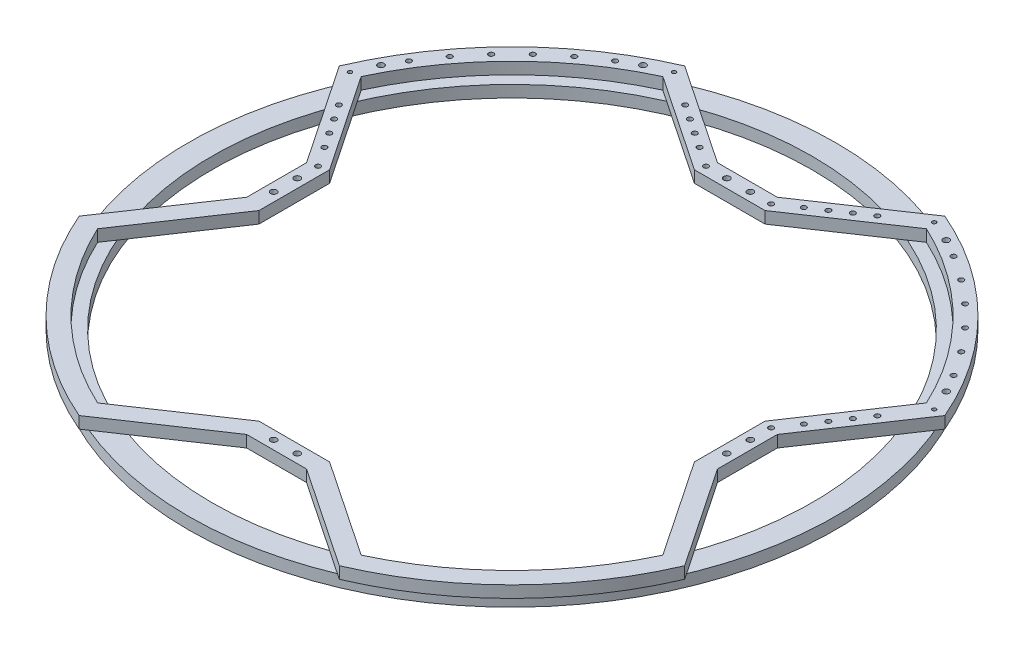
from build123d import *

# Parameters (mm, degrees)
SKETCH_1_R          = 275
SKETCH_1_R_2        = 255
EXTRUDE_1_DEPTH     = 10
EXTRUDE_2_DEPTH     = 10
SKETCH_8_R          = 2.65
SKETCH_8_R_2        = 1.65
SKETCH_8_R_3        = 2.15
CUT_EXTRUDE_1_DEPTH = 21


with BuildPart() as part:
    # 草图1 → 凸台-拉伸1 (new body)
    with BuildSketch(Plane(origin=(0, 0, 0), x_dir=(1, 0, 0), z_dir=(0, 1, 0))):
        Circle(SKETCH_1_R)
        Circle(SKETCH_1_R_2, mode=Mode.SUBTRACT)
    extrude(amount=EXTRUDE_1_DEPTH)


with BuildPart() as body_2:
    # 草图2 → 凸台-拉伸2 (new body)
    with BuildSketch(Plane(origin=(0, 10, 0), x_dir=(1, 0, 0), z_dir=(0, 1, 0))):
        with BuildLine():
            Line((-110.525139894, 257.262887824), (-25.423255477, 200))
            Line((-25.423255477, 200), (0, 200))
            Line((0, 200), (25.423255477, 200))
            Line((25.423255477, 200), (110.525139894, 257.262887824))
            ThreePointArc((110.525139894, 257.262887824), (197.989898732, 197.989898732), (257.262887824, 110.525139894))
            Line((257.262887824, 110.525139894), (200, 25.423255477))
            Line((200, 25.423255477), (200, 0))
            Line((200, 0), (200, -25.423255477))
            Line((200, -25.423255477), (257.262887824, -110.525139894))
            ThreePointArc((257.262887824, -110.525139894), (197.989898732, -197.989898732), (110.525139894, -257.262887824))
            Line((110.525139894, -257.262887824), (25.423255477, -200))
            Line((25.423255477, -200), (0, -200))
            Line((0, -200), (-25.423255477, -200))
            Line((-25.423255477, -200), (-110.525139894, -257.262887824))
            ThreePointArc((-110.525139894, -257.262887824), (-197.989898732, -197.989898732), (-257.262887824, -110.525139894))
            Line((-257.262887824, -110.525139894), (-200, -25.423255477))
            Line((-200, -25.423255477), (-200, 25.423255477))
            Line((-200, 25.423255477), (-257.262887824, 110.525139894))
            ThreePointArc((-257.262887824, 110.525139894), (-197.989898732, 197.989898732), (-110.525139894, 257.262887824))
        make_face()
        with BuildLine():
            Line((0, 185), (30, 185))
            Line((30, 185), (111.993839361, 240.171563565))
            ThreePointArc((111.993839361, 240.171563565), (187.383297014, 187.383297014), (240.171563565, 111.993839361))
            Line((240.171563565, 111.993839361), (185, 30))
            Line((185, 30), (185, 0))
            Line((185, 0), (185, -30))
            Line((185, -30), (240.171563565, -111.993839361))
            ThreePointArc((240.171563565, -111.993839361), (187.383297014, -187.383297014), (111.993839361, -240.171563565))
            Line((111.993839361, -240.171563565), (30, -185))
            Line((30, -185), (0, -185))
            Line((0, -185), (-30, -185))
            Line((-30, -185), (-111.993839361, -240.171563565))
            ThreePointArc((-111.993839361, -240.171563565), (-187.383297014, -187.383297014), (-240.171563565, -111.993839361))
            Line((-240.171563565, -111.993839361), (-185, -30))
            Line((-185, -30), (-185, 30))
            Line((-185, 30), (-240.171563565, 111.993839361))
            ThreePointArc((-240.171563565, 111.993839361), (-187.383297014, 187.383297014), (-111.993839361, 240.171563565))
            Line((-111.993839361, 240.171563565), (-30, 185))
            Line((-30, 185), (0, 185))
        make_face(mode=Mode.SUBTRACT)
    extrude(amount=EXTRUDE_2_DEPTH)

    # 草图8 → 切除-拉伸1 (cut, through all)
    with BuildSketch(Plane(origin=(0, 20, 0), x_dir=(1, 0, 0), z_dir=(0, 1, 0))):
        with Locations((-10, 192.5)):
            Circle(SKETCH_8_R)
        with Locations((10, 192.5)):
            Circle(SKETCH_8_R)
        with Locations((-10, -192.5)):
            Circle(SKETCH_8_R)
        with Locations((10, -192.5)):
            Circle(SKETCH_8_R)
        with Locations((192.5, 10)):
            Circle(SKETCH_8_R)
        with Locations((192.5, -10)):
            Circle(SKETCH_8_R)
        with Locations((-192.5, 10)):
            Circle(SKETCH_8_R)
        with Locations((-192.5, -10)):
            Circle(SKETCH_8_R)
        with Locations((-110.525139894, 248.223100485)):
            Circle(SKETCH_8_R_2)
        with Locations((-27.711627738, 192.5)):
            Circle(SKETCH_8_R_3)
        with Locations((-44.304938442, 203.665215623)):
            Circle(SKETCH_8_R_3)
        with Locations((-56.749921469, 212.03912734)):
            Circle(SKETCH_8_R_3)
        with Locations((-69.194904497, 220.413039057)):
            Circle(SKETCH_8_R_3)
        with Locations((-81.639887524, 228.786950774)):
            Circle(SKETCH_8_R_3)
        with Locations((-143.808163456, 231.45377032)):
            Circle(SKETCH_8_R_3)
        with Locations((-164.415519771, 217.299729706)):
            Circle(SKETCH_8_R_3)
        with Locations((-183.638937552, 201.316607082)):
            Circle(SKETCH_8_R_3)
        with Locations((-201.316607082, 183.638937552)):
            Circle(SKETCH_8_R_3)
        with Locations((-217.299729706, 164.415519771)):
            Circle(SKETCH_8_R_3)
        with Locations((-231.45377032, 143.808163456)):
            Circle(SKETCH_8_R_3)
        with Locations((-128.811575358, 240.123330241)):
            Circle(SKETCH_8_R)
        with Locations((-240.123330241, 128.811575358)):
            Circle(SKETCH_8_R)
        with Locations((-228.786950774, 81.639887524)):
            Circle(SKETCH_8_R_3)
        with Locations((-220.413039057, 69.194904497)):
            Circle(SKETCH_8_R_3)
        with Locations((-212.03912734, 56.749921469)):
            Circle(SKETCH_8_R_3)
        with Locations((-203.665215623, 44.304938442)):
            Circle(SKETCH_8_R_3)
        with Locations((-192.5, 27.711627738)):
            Circle(SKETCH_8_R_3)
        with Locations((-248.223100485, 110.525139894)):
            Circle(SKETCH_8_R_2)
        with Locations((192.5, 27.711627738)):
            Circle(SKETCH_8_R_3)
        with Locations((248.223100485, 110.525139894)):
            Circle(SKETCH_8_R_2)
        with Locations((203.665215623, 44.304938442)):
            Circle(SKETCH_8_R_3)
        with Locations((212.03912734, 56.749921469)):
            Circle(SKETCH_8_R_3)
        with Locations((220.413039057, 69.194904497)):
            Circle(SKETCH_8_R_3)
        with Locations((228.786950774, 81.639887524)):
            Circle(SKETCH_8_R_3)
        with Locations((240.123330241, 128.811575358)):
            Circle(SKETCH_8_R)
        with Locations((231.45377032, 143.808163456)):
            Circle(SKETCH_8_R_3)
        with Locations((128.811575358, 240.123330241)):
            Circle(SKETCH_8_R)
        with Locations((201.316607082, 183.638937552)):
            Circle(SKETCH_8_R_3)
        with Locations((183.638937552, 201.316607082)):
            Circle(SKETCH_8_R_3)
        with Locations((164.415519771, 217.299729706)):
            Circle(SKETCH_8_R_3)
        with Locations((143.808163456, 231.45377032)):
            Circle(SKETCH_8_R_3)
        with Locations((81.639887524, 228.786950774)):
            Circle(SKETCH_8_R_3)
        with Locations((69.194904497, 220.413039057)):
            Circle(SKETCH_8_R_3)
        with Locations((56.749921469, 212.03912734)):
            Circle(SKETCH_8_R_3)
        with Locations((44.304938442, 203.665215623)):
            Circle(SKETCH_8_R_3)
        with Locations((110.525139894, 248.223100485)):
            Circle(SKETCH_8_R_2)
        with Locations((27.711627738, 192.5)):
            Circle(SKETCH_8_R_3)
        with Locations((217.299729706, 164.415519771)):
            Circle(SKETCH_8_R_3)
    extrude(amount=-CUT_EXTRUDE_1_DEPTH, mode=Mode.SUBTRACT)


solid = Compound([part.part, body_2.part])
